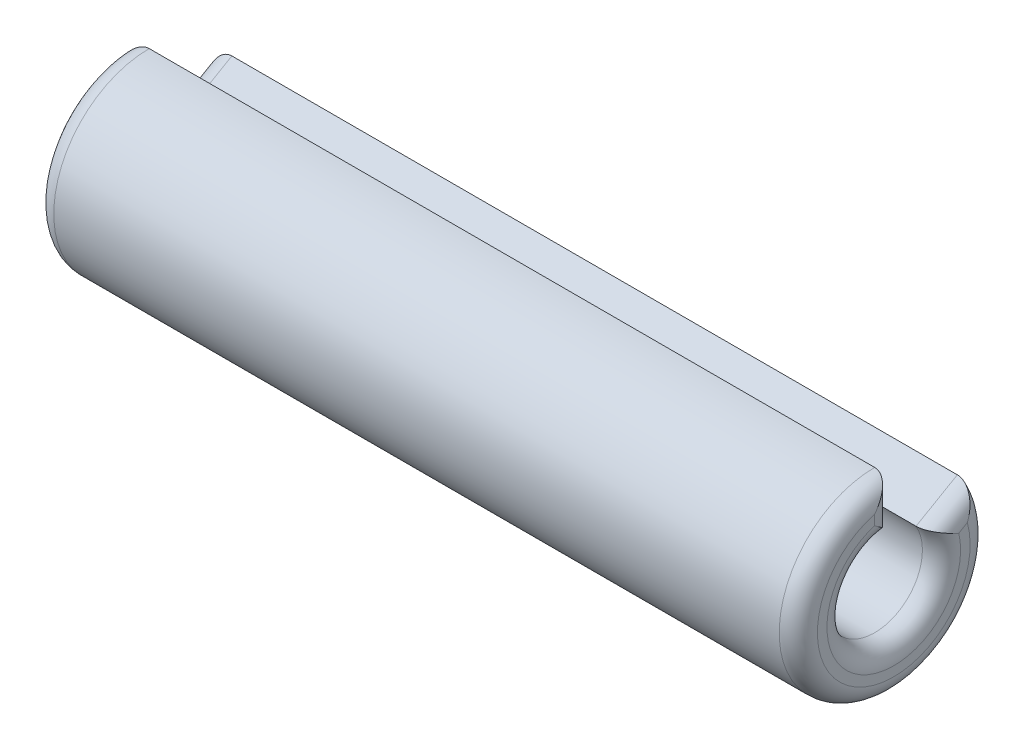
from build123d import *

# Parameters (mm, degrees)
SKETCH1_W      = 4
SKETCH1_H      = 0.25
REVOLVE1_ANGLE = 300
FILLET1_R      = 0.1


with BuildPart() as part:
    # Sketch1 → Revolve1 (revolve)
    with BuildSketch(Plane.XY):
        with Locations((0, 0.375)):
            Rectangle(SKETCH1_W, SKETCH1_H)
    revolve(axis=Axis((0, 0, 0), (1, 0, 0)), revolution_arc=REVOLVE1_ANGLE)

    # Fillet1
    fillet1_edges = [part.edges().sort_by_distance(p)[0] for p in [
        (2, 0.1875, -0.324759526),
        (-2, 0.375, 0),
        (-2, 0.1875, -0.324759526),
        (2, 0.375, 0),
        (-2, -0.433012702, 0.25),
        (2, -0.433012702, 0.25),
        (2, -0.216506351, 0.125),
        (-2, -0.216506351, 0.125),
    ]]
    fillet(fillet1_edges, radius=FILLET1_R)


solid = part.part
